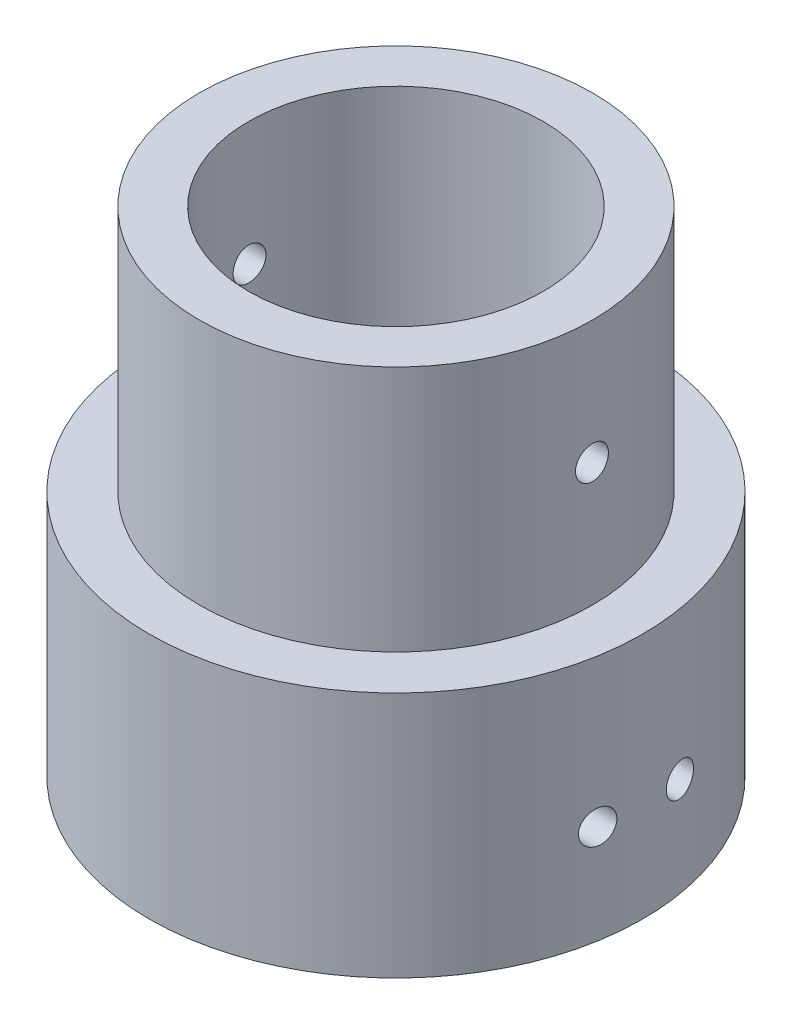
from build123d import *

# Parameters (mm, degrees)
SKETCH1_R                = 15
BOSS_EXTRUDE1_DEPTH      = 15
SKETCH2_R                = 11.95
SKETCH2_R_2              = 8.95
BOSS_EXTRUDE2_DEPTH      = 15
BOSS_EXTRUDE2_DEPTH_BACK = 3
SKETCH3_R                = 1
CUT_EXTRUDE1_DEPTH       = 16
CUT_EXTRUDE1_DEPTH_BACK  = 16
SKETCH4_R                = 11
BOSS_EXTRUDE3_DEPTH      = 5
M3_CLEARANCE_HOLE1_D     = 3.4
SKETCH8_R                = 26.295997506
CUT_EXTRUDE2_DEPTH       = 66
SKETCH9_W                = 6.2
SKETCH9_H                = 15.5
CUT_EXTRUDE3_DEPTH       = 12


with BuildPart() as part:
    # Sketch1 → Boss-Extrude1 (new body)
    with BuildSketch(Plane(origin=(0, 0, 0), x_dir=(1, 0, 0), z_dir=(0, 1, 0))):
        Circle(SKETCH1_R)
    extrude(amount=BOSS_EXTRUDE1_DEPTH)

    # Sketch2 → Boss-Extrude2 (add, two sides)
    with BuildSketch(Plane(origin=(0, 15, 0), x_dir=(1, 0, 0), z_dir=(0, 1, 0))) as boss_extrude2_sk:
        Circle(SKETCH2_R)
        Circle(SKETCH2_R_2, mode=Mode.SUBTRACT)
    extrude(amount=BOSS_EXTRUDE2_DEPTH)
    extrude(boss_extrude2_sk.sketch, amount=-BOSS_EXTRUDE2_DEPTH_BACK)

    # Sketch3 → Cut-Extrude1 (cut, two sides)
    with BuildSketch(Plane(origin=(0, 0, 0), x_dir=(0, 0, -1), z_dir=(1, 0, 0))) as cut_extrude1_sk:
        with Locations((0, 22.5)):
            Circle(SKETCH3_R)
        with Locations((-2.5, 6)):
            Circle(SKETCH3_R)
        with Locations((2.5, 6)):
            Circle(SKETCH3_R)
    extrude(amount=CUT_EXTRUDE1_DEPTH, mode=Mode.SUBTRACT)
    extrude(cut_extrude1_sk.sketch, amount=-CUT_EXTRUDE1_DEPTH_BACK, mode=Mode.SUBTRACT)

    # Sketch4 → Boss-Extrude3 (add)
    with BuildSketch(Plane(origin=(0, 0, 0), x_dir=(0, 0, -1), z_dir=(1, 0, 0))):
        with BuildLine():
            Line((11, 0), (-11, 0))
            Line((-11, 0), (-11, -12))
            ThreePointArc((-11, -12), (-12.05572809, -16.472135955), (-15, -20))
            ThreePointArc((-15, -20), (0, -65), (15, -20))
            ThreePointArc((15, -20), (12.05572809, -16.472135955), (11, -12))
            Line((11, -12), (11, 0))
        make_face()
        with Locations((0, -40)):
            Circle(SKETCH4_R, mode=Mode.SUBTRACT)
    extrude(amount=BOSS_EXTRUDE3_DEPTH)

    # M3 Clearance Hole1 (through all)
    with Locations(Plane(origin=(5, 0, 0), x_dir=(0, 0, -1), z_dir=(1, 0, 0))):
        with Locations((10.606601718, -50.606601718), (-10.606601718, -50.606601718), (-10.606601718, -29.393398282), (10.606601718, -29.393398282)):
            Hole(M3_CLEARANCE_HOLE1_D / 2)

    # Sketch8 → Cut-Extrude2 (cut, through all)
    with BuildSketch(Plane.XZ):
        Circle(SKETCH8_R)
    extrude(amount=CUT_EXTRUDE2_DEPTH, mode=Mode.SUBTRACT)

    # Sketch9 → Cut-Extrude3 (cut)
    with BuildSketch(Plane.XZ):
        with Locations((3.1, 0)):
            Rectangle(SKETCH9_W, SKETCH9_H)
    extrude(amount=-CUT_EXTRUDE3_DEPTH, mode=Mode.SUBTRACT)


solid = part.part
